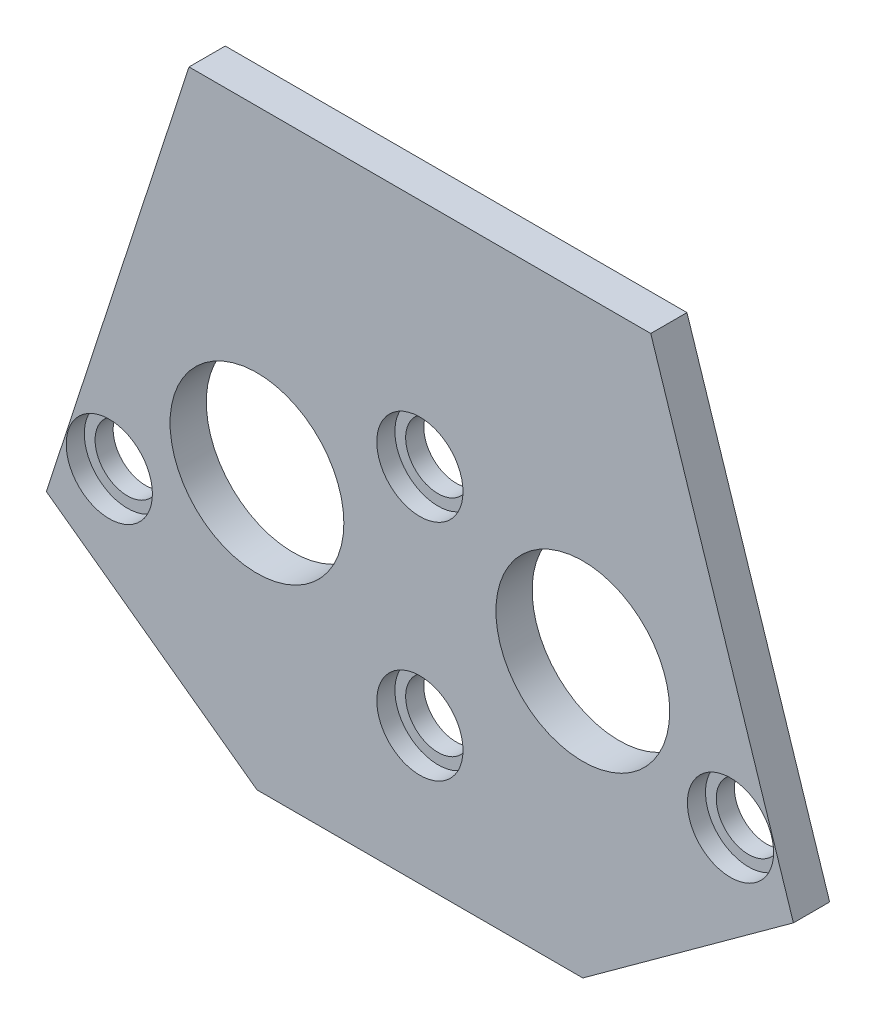
from build123d import *

# Parameters (mm, degrees)
SKETCH2_R           = 4.7625
SKETCH2_R_2         = 12.8
BOSS_EXTRUDE2_DEPTH = 5.334
CUT_EXTRUDE3_START  = -2.667
SKETCH3_R           = 6.35
SKETCH3_R_2         = 4.7625
CUT_EXTRUDE3_DEPTH  = 2.667
SKETCH3_2_R         = 4.7625
CUT_EXTRUDE4_DEPTH  = 87.872399887


with BuildPart() as part:
    # Sketch2 → Boss-Extrude2 (new body)
    with BuildSketch(Plane.XY):
        Polygon((-55.022779977, 2.330692017), (-24, -20.208676973), (24, -20.208676973), (55.022779977, 2.330692017), (34.005948181, 67.013849238), (-34.005948181, 67.013849238), align=None)
        Circle(SKETCH2_R, mode=Mode.SUBTRACT)
        with Locations((-24, 20.208676973)):
            Circle(SKETCH2_R_2, mode=Mode.SUBTRACT)
        with Locations((24, 20.208676973)):
            Circle(SKETCH2_R_2, mode=Mode.SUBTRACT)
    extrude(amount=BOSS_EXTRUDE2_DEPTH)

    # Sketch3 → Cut-Extrude3 (cut)
    # profile 1 of 4: a face of its own
    with BuildSketch(Plane.XY.offset(5.334).offset(CUT_EXTRUDE3_START)):
        Circle(SKETCH3_R)
        Circle(SKETCH3_R_2, mode=Mode.SUBTRACT)
    # profile 2 of 4: a face of its own
    with BuildSketch(Plane.XY.offset(5.334).offset(CUT_EXTRUDE3_START)):
        with Locations((45.751679669, 9.848845061)):
            Circle(SKETCH3_R)
        with Locations((45.751679669, 9.848845061)):
            Circle(SKETCH3_R_2, mode=Mode.SUBTRACT)
    # profile 3 of 4: a face of its own
    with BuildSketch(Plane.XY.offset(5.334).offset(CUT_EXTRUDE3_START)):
        with Locations((0, 33.008676973)):
            Circle(SKETCH3_R)
        with Locations((0, 33.008676973)):
            Circle(SKETCH3_R_2, mode=Mode.SUBTRACT)
    # profile 4 of 4: a face of its own
    with BuildSketch(Plane.XY.offset(5.334).offset(CUT_EXTRUDE3_START)):
        with Locations((-45.751679669, 9.848845061)):
            Circle(SKETCH3_R)
        with Locations((-45.751679669, 9.848845061)):
            Circle(SKETCH3_R_2, mode=Mode.SUBTRACT)
    extrude(amount=CUT_EXTRUDE3_DEPTH, mode=Mode.SUBTRACT)

    # Sketch3_2 → Cut-Extrude4 (cut, through all)
    with BuildSketch(Plane.XY.offset(5.334)):
        with Locations((45.751679669, 9.848845061)):
            Circle(SKETCH3_2_R)
        with Locations((0, 33.008676973)):
            Circle(SKETCH3_2_R)
        with Locations((-45.751679669, 9.848845061)):
            Circle(SKETCH3_2_R)
    extrude(amount=-CUT_EXTRUDE4_DEPTH, mode=Mode.SUBTRACT)


solid = part.part
